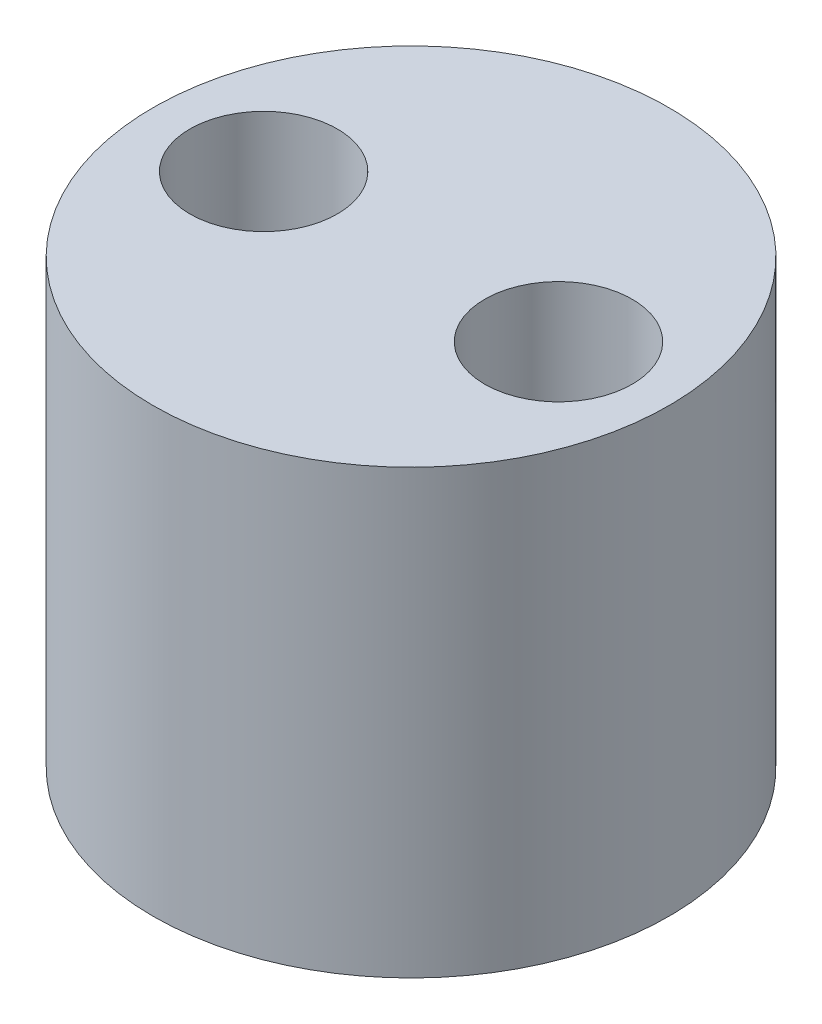
from build123d import *

# Parameters (mm, degrees)
SKETCH1_R           = 44.45
SKETCH1_R_2         = 12.7
BOSS_EXTRUDE2_DEPTH = 76.2


with BuildPart() as part:
    # Sketch1 → Boss-Extrude2 (new body)
    with BuildSketch(Plane(origin=(0, 0, 0), x_dir=(1, 0, 0), z_dir=(0, 1, 0))):
        Circle(SKETCH1_R)
        with Locations((-25.4, 0)):
            Circle(SKETCH1_R_2, mode=Mode.SUBTRACT)
        with Locations((25.4, 0)):
            Circle(SKETCH1_R_2, mode=Mode.SUBTRACT)
    extrude(amount=BOSS_EXTRUDE2_DEPTH)


solid = part.part
